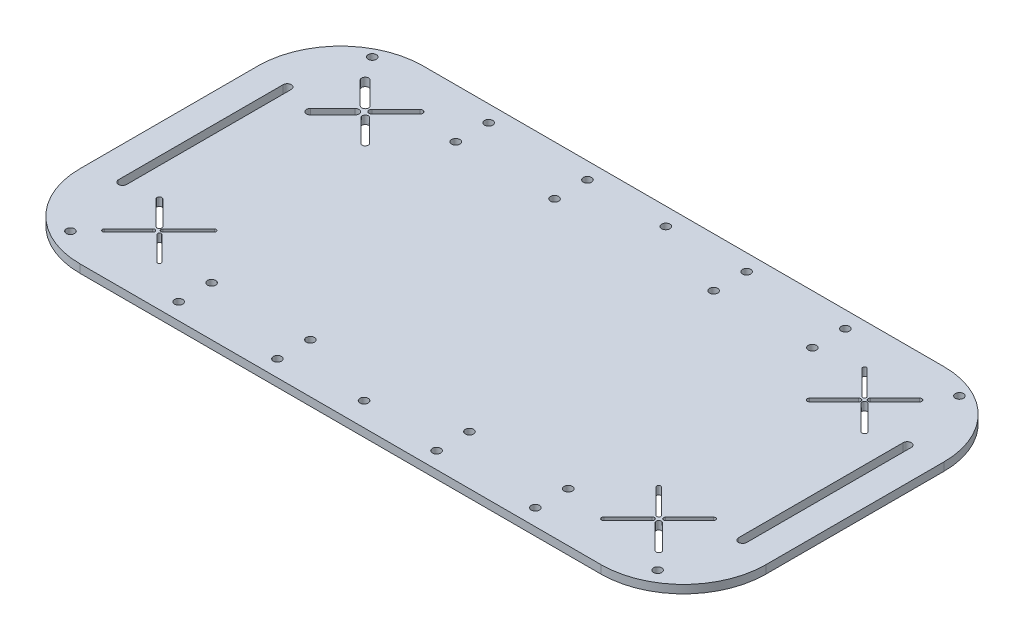
from build123d import *

# Parameters (mm, degrees)
EXTRUDE_1_DEPTH     = 3
SKETCH_2_R          = 1.5
CUT_EXTRUDE_1_DEPTH = 3
CUT_EXTRUDE_2_DEPTH = 10
SKETCH_4_R          = 1.5
CUT_EXTRUDE_3_DEPTH = 4
SKETCH_5_R          = 1.5
CUT_EXTRUDE_4_DEPTH = 10
SKETCH_6_R          = 1.5
CUT_EXTRUDE_5_DEPTH = 10


with BuildPart() as part:
    # 草图1 → 凸台-拉伸1 (new body)
    with BuildSketch(Plane(origin=(0, 0, 0), x_dir=(1, 0, 0), z_dir=(0, 1, 0))):
        with BuildLine():
            Line((-108.354700855, 61.431623932), (81.645299145, 61.431623932))
            ThreePointArc((81.645299145, 61.431623932), (102.858502581, 52.644827367), (111.645299145, 31.431623932))
            Line((111.645299145, 31.431623932), (111.645299145, -33.568376068))
            ThreePointArc((111.645299145, -33.568376068), (102.858502581, -54.781579504), (81.645299145, -63.568376068))
            Line((81.645299145, -63.568376068), (-108.354700855, -63.568376068))
            ThreePointArc((-108.354700855, -63.568376068), (-129.56790429, -54.781579504), (-138.354700855, -33.568376068))
            Line((-138.354700855, -33.568376068), (-138.354700855, 31.431623932))
            ThreePointArc((-138.354700855, 31.431623932), (-129.56790429, 52.644827367), (-108.354700855, 61.431623932))
        make_face()
    extrude(amount=EXTRUDE_1_DEPTH)

    # 草图2 → 切除-拉伸1 (cut)
    with BuildSketch(Plane(origin=(0, 3, 0), x_dir=(1, 0, 0), z_dir=(0, 1, 0))):
        with Locations((-78.354700855, -45.568376068)):
            Circle(SKETCH_2_R)
        with Locations((-78.354700855, -57.568376068)):
            Circle(SKETCH_2_R)
        with Locations((51.645299145, -45.568376068)):
            Circle(SKETCH_2_R)
        with Locations((51.645299145, -57.568376068)):
            Circle(SKETCH_2_R)
        with Locations((-78.354700855, 55.431623932)):
            Circle(SKETCH_2_R)
        with Locations((-78.354700855, 43.431623932)):
            Circle(SKETCH_2_R)
        with Locations((51.645299145, 43.431623932)):
            Circle(SKETCH_2_R)
        with Locations((51.645299145, 55.431623932)):
            Circle(SKETCH_2_R)
    extrude(amount=-CUT_EXTRUDE_1_DEPTH, mode=Mode.SUBTRACT)

    # 草图3 → 切除-拉伸2 (cut)
    with BuildSketch(Plane(origin=(0, 3, 0), x_dir=(1, 0, 0), z_dir=(0, 1, 0))):
        with BuildLine():
            Line((-127.854700855, -30), (-127.854700855, 30))
            ThreePointArc((-127.854700855, 30), (-126.354700855, 31.5), (-124.854700855, 30))
            Line((-124.854700855, 30), (-124.854700855, -30))
            ThreePointArc((-124.854700855, -30), (-126.354700855, -31.5), (-127.854700855, -30))
        make_face()
        with BuildLine():
            Line((98.145299145, -30), (98.145299145, 30))
            ThreePointArc((98.145299145, 30), (99.645299145, 31.5), (101.145299145, 30))
            Line((101.145299145, 30), (101.145299145, -30))
            ThreePointArc((101.145299145, -30), (99.645299145, -31.5), (98.145299145, -30))
        make_face()
        with BuildLine():
            Line((-114.900254633, -48.02282229), (-106.12832787, -39.250895528))
            ThreePointArc((-106.12832787, -39.250895528), (-105.037220314, -39.250895528), (-105.037220314, -40.342003084))
            Line((-105.037220314, -40.342003084), (-113.809147077, -49.113929846))
            ThreePointArc((-113.809147077, -49.113929846), (-114.900254633, -49.113929846), (-114.900254633, -48.02282229))
        make_face()
        with BuildLine():
            Line((-106.195945183, -37.953473922), (-114.967871946, -29.181547159))
            ThreePointArc((-114.967871946, -29.181547159), (-114.967871946, -27.955204977), (-113.741529764, -27.955204977))
            Line((-113.741529764, -27.955204977), (-104.969603001, -36.72713174))
            ThreePointArc((-104.969603001, -36.72713174), (-104.969603001, -37.953473922), (-106.195945183, -37.953473922))
        make_face()
        with BuildLine():
            Line((-102.683942112, -39.353763801), (-93.91201535, -48.125690563))
            ThreePointArc((-93.91201535, -48.125690563), (-93.91201535, -49.011061573), (-94.79738636, -49.011061573))
            Line((-94.79738636, -49.011061573), (-103.569313122, -40.239134811))
            ThreePointArc((-103.569313122, -40.239134811), (-103.569313122, -39.353763801), (-102.683942112, -39.353763801))
        make_face()
        with BuildLine():
            Line((-104.217158252, -37.476114378), (-94.832060398, -28.091016525))
            ThreePointArc((-94.832060398, -28.091016525), (-93.877341311, -28.091016525), (-93.877341311, -29.045735612))
            Line((-93.877341311, -29.045735612), (-103.262439165, -38.430833465))
            ThreePointArc((-103.262439165, -38.430833465), (-104.217158252, -38.430833465), (-104.217158252, -37.476114378))
        make_face()
        with BuildLine():
            Line((-115.372891691, 27.449814768), (-107.214136019, 35.60857044))
            ThreePointArc((-107.214136019, 35.60857044), (-105.177754347, 35.60857044), (-105.177754347, 33.572188767))
            Line((-105.177754347, 33.572188767), (-113.336510018, 25.413433095))
            ThreePointArc((-113.336510018, 25.413433095), (-115.372891691, 25.413433095), (-115.372891691, 27.449814768))
        make_face()
        with BuildLine():
            Line((-107.107809328, 37.361004116), (-115.266564999, 45.519759787))
            ThreePointArc((-115.266564999, 45.519759787), (-115.266564999, 47.343488076), (-113.44283671, 47.343488076))
            Line((-113.44283671, 47.343488076), (-105.284081039, 39.184732404))
            ThreePointArc((-105.284081039, 39.184732404), (-105.284081039, 37.361004116), (-107.107809328, 37.361004116))
        make_face()
        with BuildLine():
            Line((-103.88351943, 38.361678912), (-95.084137633, 47.16106071))
            ThreePointArc((-95.084137633, 47.16106071), (-93.625264077, 47.16106071), (-93.625264077, 45.702187154))
            Line((-93.625264077, 45.702187154), (-102.424645874, 36.902805357))
            ThreePointArc((-102.424645874, 36.902805357), (-103.88351943, 36.902805357), (-103.88351943, 38.361678912))
        make_face()
        with BuildLine():
            Line((-101.717094005, 35.386742124), (-93.558338334, 27.227986453))
            ThreePointArc((-93.558338334, 27.227986453), (-93.558338334, 25.635261411), (-95.151063376, 25.635261411))
            Line((-95.151063376, 25.635261411), (-103.309819047, 33.794017082))
            ThreePointArc((-103.309819047, 33.794017082), (-103.309819047, 35.386742124), (-101.717094005, 35.386742124))
        make_face()
        with BuildLine():
            Line((67.051420942, -47.974497865), (75.823347705, -39.202571103))
            ThreePointArc((75.823347705, -39.202571103), (77.011104111, -39.202571103), (77.011104111, -40.390327509))
            Line((77.011104111, -40.390327509), (68.239177348, -49.162254271))
            ThreePointArc((68.239177348, -49.162254271), (67.051420942, -49.162254271), (67.051420942, -47.974497865))
        make_face()
        with BuildLine():
            Line((76.026361578, -38.002790255), (67.118623268, -29.095051945))
            ThreePointArc((67.118623268, -29.095051945), (67.118623268, -28.041700191), (68.171975022, -28.041700191))
            Line((68.171975022, -28.041700191), (77.079713332, -36.949438501))
            ThreePointArc((77.079713332, -36.949438501), (77.079713332, -38.002790255), (76.026361578, -38.002790255))
        make_face()
        with BuildLine():
            Line((79.555520355, -39.114301334), (88.327447117, -47.886228097))
            ThreePointArc((88.327447117, -47.886228097), (88.327447117, -49.25052404), (86.963151173, -49.25052404))
            Line((86.963151173, -49.25052404), (78.191224411, -40.478597278))
            ThreePointArc((78.191224411, -40.478597278), (78.191224411, -39.114301334), (79.555520355, -39.114301334))
        make_face()
        with BuildLine():
            Line((78.357230227, -36.824160675), (87.12915699, -28.052233913))
            ThreePointArc((87.12915699, -28.052233913), (88.161441301, -28.052233913), (88.161441301, -29.084518224))
            Line((88.161441301, -29.084518224), (79.389514538, -37.856444987))
            ThreePointArc((79.389514538, -37.856444987), (78.357230227, -37.856444987), (78.357230227, -36.824160675))
        make_face()
        with BuildLine():
            Line((67.041358523, 27.035564554), (75.949096833, 35.943302864))
            ThreePointArc((75.949096833, 35.943302864), (77.156978077, 35.943302864), (77.156978077, 34.73542162))
            Line((77.156978077, 34.73542162), (68.249239767, 25.82768331))
            ThreePointArc((68.249239767, 25.82768331), (67.041358523, 25.82768331), (67.041358523, 27.035564554))
        make_face()
        with BuildLine():
            Line((76.086975669, 37.057823836), (67.179237359, 45.965562146))
            ThreePointArc((67.179237359, 45.965562146), (67.179237359, 46.897685718), (68.111360931, 46.897685718))
            Line((68.111360931, 46.897685718), (77.019099241, 37.989947408))
            ThreePointArc((77.019099241, 37.989947408), (77.019099241, 37.057823836), (76.086975669, 37.057823836))
        make_face()
        with BuildLine():
            Line((79.385756077, 35.987557483), (88.293494387, 27.079819173))
            ThreePointArc((88.293494387, 27.079819173), (88.293494387, 25.78342869), (86.997103904, 25.78342869))
            Line((86.997103904, 25.78342869), (78.089365594, 34.691167))
            ThreePointArc((78.089365594, 34.691167), (78.089365594, 35.987557483), (79.385756077, 35.987557483))
        make_face()
        with BuildLine():
            Line((78.097193522, 38.164252935), (87.004931832, 47.071991245))
            ThreePointArc((87.004931832, 47.071991245), (88.285666458, 47.071991245), (88.285666458, 45.791256619))
            Line((88.285666458, 45.791256619), (79.377928148, 36.883518309))
            ThreePointArc((79.377928148, 36.883518309), (78.097193522, 36.883518309), (78.097193522, 38.164252935))
        make_face()
    extrude(amount=-CUT_EXTRUDE_2_DEPTH, mode=Mode.SUBTRACT)

    # 草图4 → 切除-拉伸3 (cut, through all)
    with BuildSketch(Plane(origin=(0, 3, 0), x_dir=(1, 0, 0), z_dir=(0, 1, 0))):
        with Locations((93.645299145, -55)):
            Circle(SKETCH_4_R)
        with Locations((93.645299145, 55)):
            Circle(SKETCH_4_R)
        with Locations((-120.354700855, 55)):
            Circle(SKETCH_4_R)
        with Locations((-120.354700855, -55)):
            Circle(SKETCH_4_R)
    extrude(amount=-CUT_EXTRUDE_3_DEPTH, mode=Mode.SUBTRACT)

    # 草图5 → 切除-拉伸4 (cut)
    with BuildSketch(Plane.XZ):
        with Locations((-13.354700855, 55)):
            Circle(SKETCH_5_R)
        with Locations((-13.354700855, -55)):
            Circle(SKETCH_5_R)
    extrude(amount=-CUT_EXTRUDE_4_DEPTH, mode=Mode.SUBTRACT)

    # 草图6 → 切除-拉伸5 (cut)
    with BuildSketch(Plane(origin=(0, 3, 0), x_dir=(1, 0, 0), z_dir=(0, 1, 0))):
        with Locations((15.645299145, 55.431623932)):
            Circle(SKETCH_6_R)
        with Locations((15.645299145, 43.431623932)):
            Circle(SKETCH_6_R)
        with Locations((15.645299145, -45.568376068)):
            Circle(SKETCH_6_R)
        with Locations((15.645299145, -57.568376068)):
            Circle(SKETCH_6_R)
        with Locations((-42.354700855, -45.568376068)):
            Circle(SKETCH_6_R)
        with Locations((-42.354700855, -57.568376068)):
            Circle(SKETCH_6_R)
        with Locations((-42.354700855, 55.431623932)):
            Circle(SKETCH_6_R)
        with Locations((-42.354700855, 43.431623932)):
            Circle(SKETCH_6_R)
    extrude(amount=-CUT_EXTRUDE_5_DEPTH, mode=Mode.SUBTRACT)


solid = part.part
